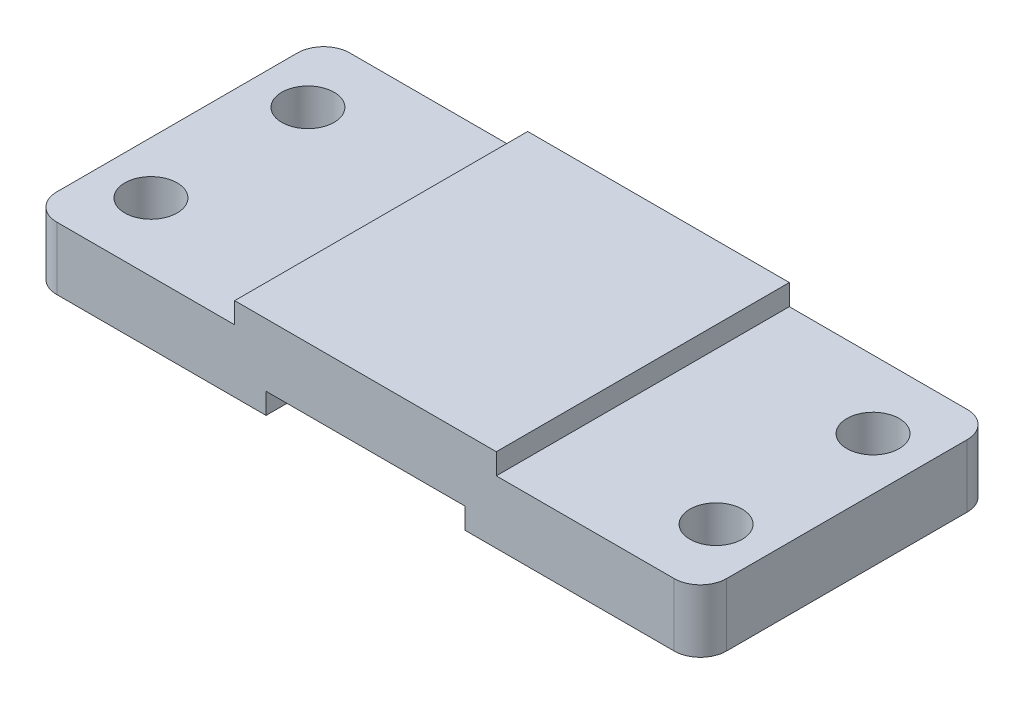
from build123d import *

# Parameters (mm, degrees)
Y_KSEKLIK_EKSTR_ZYON1_DEPTH = 12
IZIM2_W                     = 50
IZIM2_H                     = 56
Y_KSEKLIK_EKSTR_ZYON2_DEPTH = 4
IZIM3_W                     = 38
IZIM3_H                     = 4
KES_EKSTR_ZYON1_DEPTH       = 56
IZIM4_R                     = 5
KES_EKSTR_ZYON2_DEPTH       = 56
KES_EKSTR_ZYON3_DEPTH       = 56


with BuildPart() as part:
    # Çizim1 → Yükseklik-Ekstrüzyon1 (new body)
    with BuildSketch(Plane(origin=(0, 0, 0), x_dir=(1, 0, 0), z_dir=(0, 1, 0))):
        Polygon((69.99751861, 24.903225806), (69.99751861, -31.096774194), (-58.00248139, -31.096774194), (-58.00248139, 24.903225806), (-19.00248139, 24.903225806), (30.99751861, 24.903225806), align=None)
    extrude(amount=Y_KSEKLIK_EKSTR_ZYON1_DEPTH)

    # Çizim2 → Yükseklik-Ekstrüzyon2 (add)
    with BuildSketch(Plane(origin=(0, 12, 0), x_dir=(1, 0, 0), z_dir=(0, 1, 0))):
        with Locations((5.99751861, -3.096774194)):
            Rectangle(IZIM2_W, IZIM2_H)
    extrude(amount=Y_KSEKLIK_EKSTR_ZYON2_DEPTH)

    # Çizim3 → Kes-Ekstrüzyon1 (cut)
    with BuildSketch(Plane.XY.offset(31.096774194)):
        with Locations((5.99751861, 2)):
            Rectangle(IZIM3_W, IZIM3_H)
    extrude(amount=-KES_EKSTR_ZYON1_DEPTH, mode=Mode.SUBTRACT)

    # Çizim4 → Kes-Ekstrüzyon2 (cut)
    with BuildSketch(Plane(origin=(0, 12, 0), x_dir=(1, 0, 0), z_dir=(0, 1, 0))):
        with Locations((-48.00248139, 11.903225806)):
            Circle(IZIM4_R)
        with Locations((-48.00248139, -18.096774194)):
            Circle(IZIM4_R)
        with Locations((59.99751861, -18.096774194)):
            Circle(IZIM4_R)
        with Locations((59.99751861, 11.903225806)):
            Circle(IZIM4_R)
    extrude(amount=-KES_EKSTR_ZYON2_DEPTH, mode=Mode.SUBTRACT)

    # Çizim5 → Kes-Ekstrüzyon3 (cut)
    with BuildSketch(Plane(origin=(0, 12, 0), x_dir=(1, 0, 0), z_dir=(0, 1, 0))):
        with BuildLine():
            Line((-58.00248139, 19.903225806), (-58.00248139, 24.903225806))
            Line((-58.00248139, 24.903225806), (-53.00248139, 24.903225806))
            ThreePointArc((-53.00248139, 24.903225806), (-56.538015296, 23.438759712), (-58.00248139, 19.903225806))
        make_face()
        with BuildLine():
            Line((69.99751861, -26.096774194), (69.99751861, -31.096774194))
            Line((69.99751861, -31.096774194), (64.99751861, -31.096774194))
            ThreePointArc((64.99751861, -31.096774194), (68.533052516, -29.632308099), (69.99751861, -26.096774194))
        make_face()
        with BuildLine():
            Line((-58.00248139, -31.096774194), (-53.00248139, -31.096774194))
            ThreePointArc((-53.00248139, -31.096774194), (-56.538015296, -29.632308099), (-58.00248139, -26.096774194))
            Line((-58.00248139, -26.096774194), (-58.00248139, -31.096774194))
        make_face()
        with BuildLine():
            Line((69.99751861, 24.903225806), (64.99751861, 24.903225806))
            ThreePointArc((64.99751861, 24.903225806), (68.533052516, 23.438759712), (69.99751861, 19.903225806))
            Line((69.99751861, 19.903225806), (69.99751861, 24.903225806))
        make_face()
    extrude(amount=-KES_EKSTR_ZYON3_DEPTH, mode=Mode.SUBTRACT)


solid = part.part
